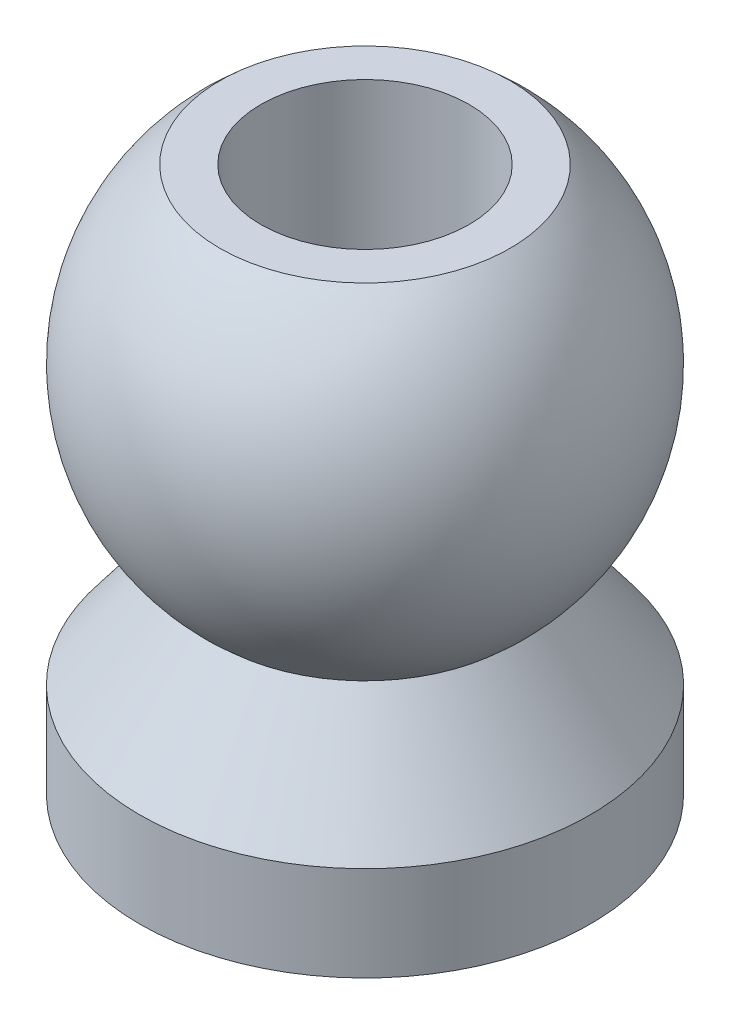
from build123d import *


with BuildPart() as part:
    # Sketch2 → Ball Link (revolve)
    with BuildSketch(Plane.XY):
        with BuildLine():
            Line((-1.1, -3.94), (-2.38, -3.94))
            Line((-2.38, -3.94), (-2.38, -2.94))
            Line((-2.38, -2.94), (-1.533623161, -1.82))
            ThreePointArc((-1.533623161, -1.82), (-2.38, 0), (-1.533623161, 1.82))
            Line((-1.533623161, 1.82), (-1.1, 1.82))
            Line((-1.1, 1.82), (-1.1, -3.94))
        make_face()
    revolve(axis=Axis((0, 4.380472835, 0), (0, -1, 0)))


solid = part.part
